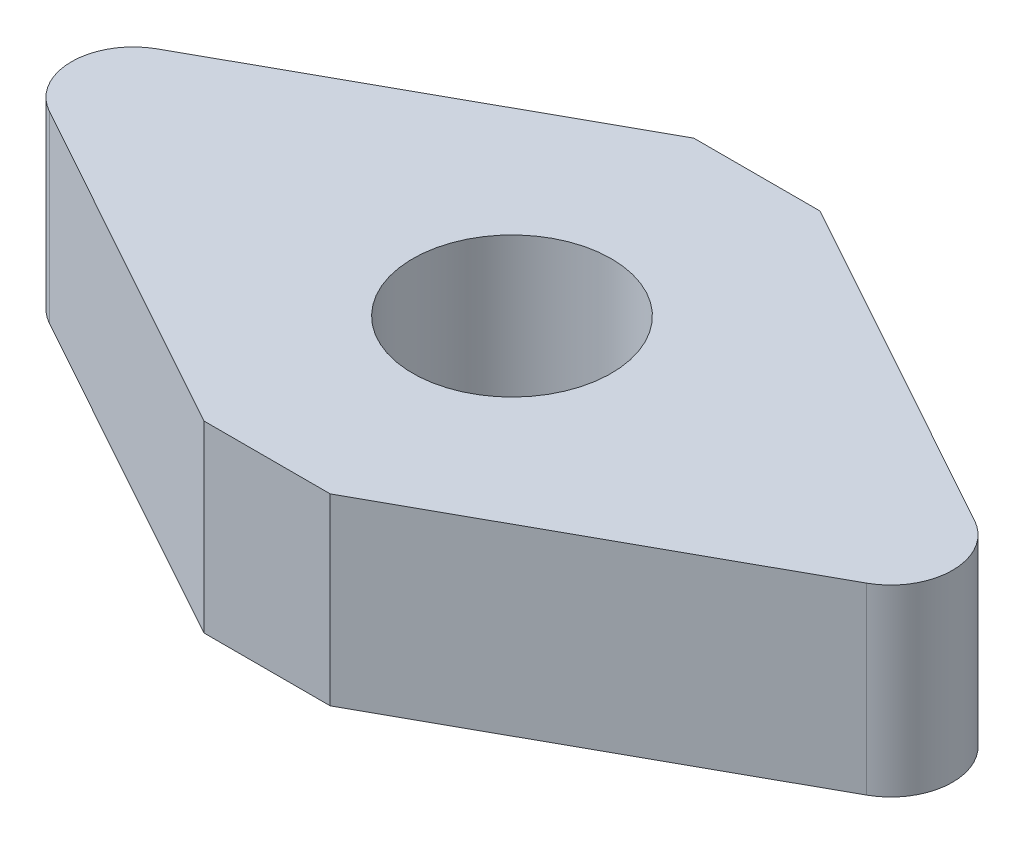
from build123d import *

# Parameters (mm, degrees)
AUFSATZ_LINEAR_AUSTRAGEN1_DEPTH = 4.76
SKIZZE2_R                       = 2.575
SCHNITT_LINEAR_AUSTRAGEN2_DEPTH = 4.76


with BuildPart() as part:
    # Skizze1 → Aufsatz-Linear austragen1 (new body)
    with BuildSketch(Plane(origin=(0, 0, 0), x_dir=(1, 0, 0), z_dir=(0, 1, 0))):
        with BuildLine():
            Line((1.637816376, 6.35), (10.594588216, 1.400399316))
            ThreePointArc((10.594588216, 1.400399316), (11.420713706, 0), (10.594588216, -1.400399316))
            Line((10.594588216, -1.400399316), (1.637816376, -6.35))
            Line((1.637816376, -6.35), (-1.637816376, -6.35))
            Line((-1.637816376, -6.35), (-10.594588216, -1.400399316))
            ThreePointArc((-10.594588216, -1.400399316), (-11.420713706, 0), (-10.594588216, 1.400399316))
            Line((-10.594588216, 1.400399316), (-1.637816376, 6.35))
            Line((-1.637816376, 6.35), (1.637816376, 6.35))
        make_face()
    extrude(amount=AUFSATZ_LINEAR_AUSTRAGEN1_DEPTH)

    # Skizze2 → Schnitt-Linear austragen2 (cut)
    with BuildSketch(Plane(origin=(0, 0, 0), x_dir=(-1, 0, 0), z_dir=(0, -1, 0))):
        with Locations(Location((0, 0, 0), (0, 0, 90))):  # turned: the seam where the file's is
            Circle(SKIZZE2_R)
    extrude(amount=-SCHNITT_LINEAR_AUSTRAGEN2_DEPTH, mode=Mode.SUBTRACT)


solid = part.part
